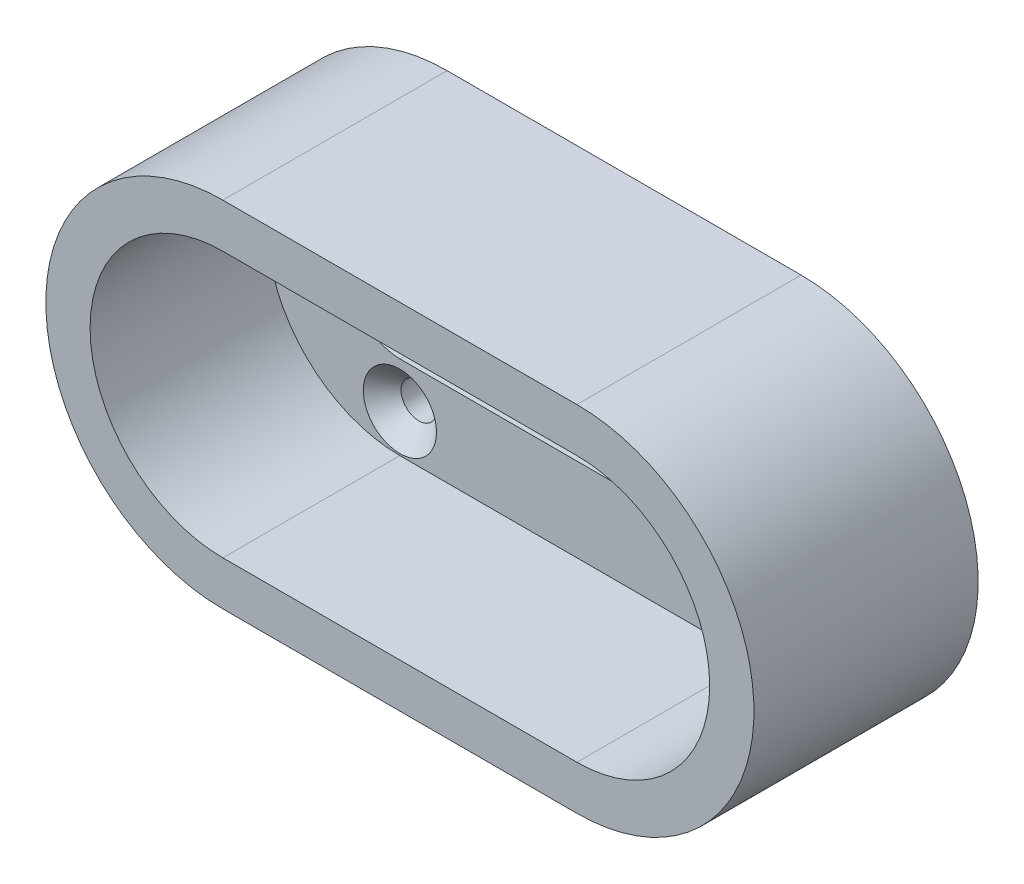
from build123d import *

# Parameters (mm, degrees)
SKETCH2_R           = 1.5
BOSS_EXTRUDE1_DEPTH = 4
BOSS_EXTRUDE2_DEPTH = 15
CHAMFER1_SIZE       = 1.6


with BuildPart() as part:
    # Sketch2 → Boss-Extrude1 (new body)
    with BuildSketch(Plane.XY):
        with BuildLine():
            Line((-15, 15), (15, 15))
            ThreePointArc((15, 15), (30, 0), (15, -15))
            Line((15, -15), (-15, -15))
            ThreePointArc((-15, -15), (-30, 0), (-15, 15))
        make_face()
        with Locations((-15, 8)):
            Circle(SKETCH2_R, mode=Mode.SUBTRACT)
        with Locations((-23, 0)):
            Circle(SKETCH2_R, mode=Mode.SUBTRACT)
        with Locations((-15, -8)):
            Circle(SKETCH2_R, mode=Mode.SUBTRACT)
        with Locations((15, -8)):
            Circle(SKETCH2_R, mode=Mode.SUBTRACT)
        with Locations((23, 0)):
            Circle(SKETCH2_R, mode=Mode.SUBTRACT)
        with Locations((15, 8)):
            Circle(SKETCH2_R, mode=Mode.SUBTRACT)
        with BuildLine():
            Line((-15, 4.15), (15, 4.15))
            ThreePointArc((15, 4.15), (19.15, 0), (15, -4.15))
            Line((15, -4.15), (-15, -4.15))
            ThreePointArc((-15, -4.15), (-19.15, 0), (-15, 4.15))
        make_face(mode=Mode.SUBTRACT)
    extrude(amount=BOSS_EXTRUDE1_DEPTH)

    # Sketch3 → Boss-Extrude2 (add)
    with BuildSketch(Plane.XY.offset(4)):
        with BuildLine():
            Line((-15, -15), (15, -15))
            ThreePointArc((15, -15), (30, 0), (15, 15))
            Line((15, 15), (-15, 15))
            ThreePointArc((-15, 15), (-30, 0), (-15, -15))
        make_face()
        with BuildLine():
            Line((-15, 11.25), (15, 11.25))
            ThreePointArc((15, 11.25), (26.25, 0), (15, -11.25))
            Line((15, -11.25), (-15, -11.25))
            ThreePointArc((-15, -11.25), (-26.25, 0), (-15, 11.25))
        make_face(mode=Mode.SUBTRACT)
    extrude(amount=BOSS_EXTRUDE2_DEPTH)

    # Chamfer1
    chamfer1_edges = [part.edges().sort_by_distance(p)[0] for p in [
        (-16.5, 8, 4),
        (-24.5, 0, 4),
        (-16.5, -8, 4),
        (13.5, -8, 4),
        (21.5, 0, 4),
        (13.5, 8, 4),
    ]]
    chamfer(chamfer1_edges, length=CHAMFER1_SIZE)


solid = part.part
